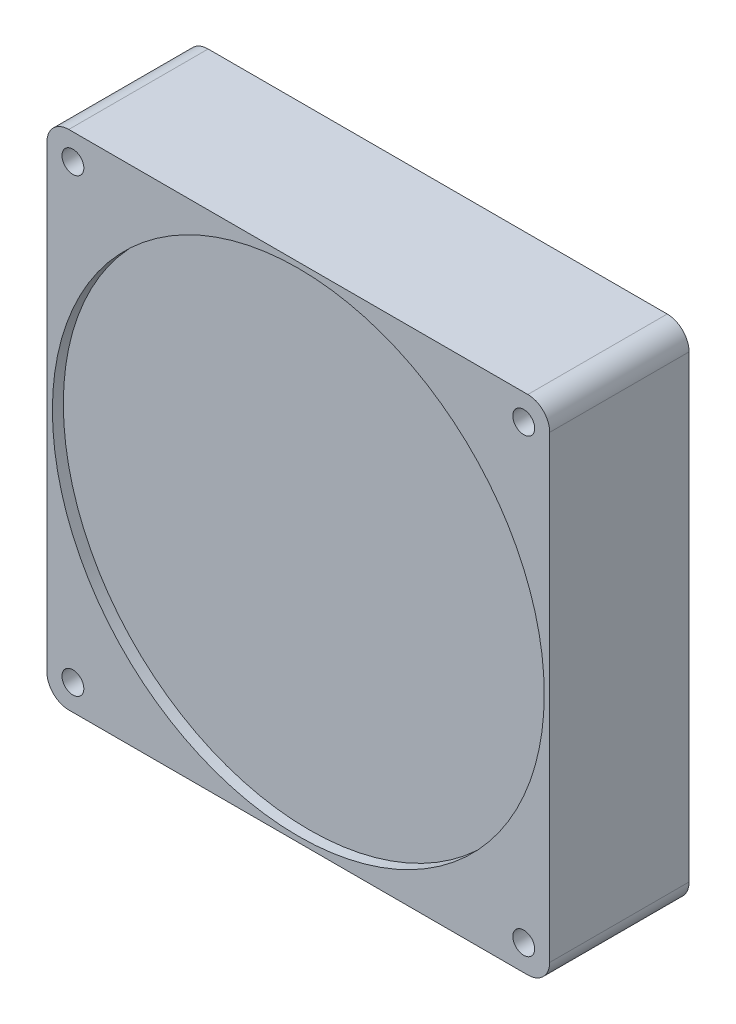
from build123d import *

# Parameters (mm, degrees)
SKETCH1_W           = 92
SKETCH1_H           = 92
BOSS_EXTRUDE1_DEPTH = 25.5
SKETCH2_R           = 2
CUT_EXTRUDE1_DEPTH  = 26.5
FILLET1_R           = 4
SKETCH3_R           = 45
CUT_EXTRUDE2_DEPTH  = 2
SKETCH4_R           = 45
CUT_EXTRUDE3_DEPTH  = 2


with BuildPart() as part:
    # Sketch1 → Boss-Extrude1 (new body)
    with BuildSketch(Plane.XY):
        Rectangle(SKETCH1_W, SKETCH1_H)
    extrude(amount=BOSS_EXTRUDE1_DEPTH)

    # Sketch2 → Cut-Extrude1 (cut, through all)
    with BuildSketch(Plane.XY.offset(25.5)):
        with Locations((-41.25, 41.25)):
            Circle(SKETCH2_R)
        with Locations((41.25, 41.25)):
            Circle(SKETCH2_R)
        with Locations((41.25, -41.25)):
            Circle(SKETCH2_R)
        with Locations((-41.25, -41.25)):
            Circle(SKETCH2_R)
    extrude(amount=-CUT_EXTRUDE1_DEPTH, mode=Mode.SUBTRACT)

    # Fillet1
    fillet1_edges = [part.edges().sort_by_distance(p)[0] for p in [
        (46, -46, 12.75),
        (-46, -46, 12.75),
        (-46, 46, 12.75),
        (46, 46, 12.75),
    ]]
    fillet(fillet1_edges, radius=FILLET1_R)

    # Sketch3 → Cut-Extrude2 (cut)
    with BuildSketch(Plane.XY.offset(25.5)):
        Circle(SKETCH3_R)
    extrude(amount=-CUT_EXTRUDE2_DEPTH, mode=Mode.SUBTRACT)

    # Sketch4 → Cut-Extrude3 (cut)
    with BuildSketch(Plane(origin=(0, 0, 0), x_dir=(-1, 0, 0), z_dir=(0, 0, -1))):
        Circle(SKETCH4_R)
    extrude(amount=-CUT_EXTRUDE3_DEPTH, mode=Mode.SUBTRACT)


solid = part.part
